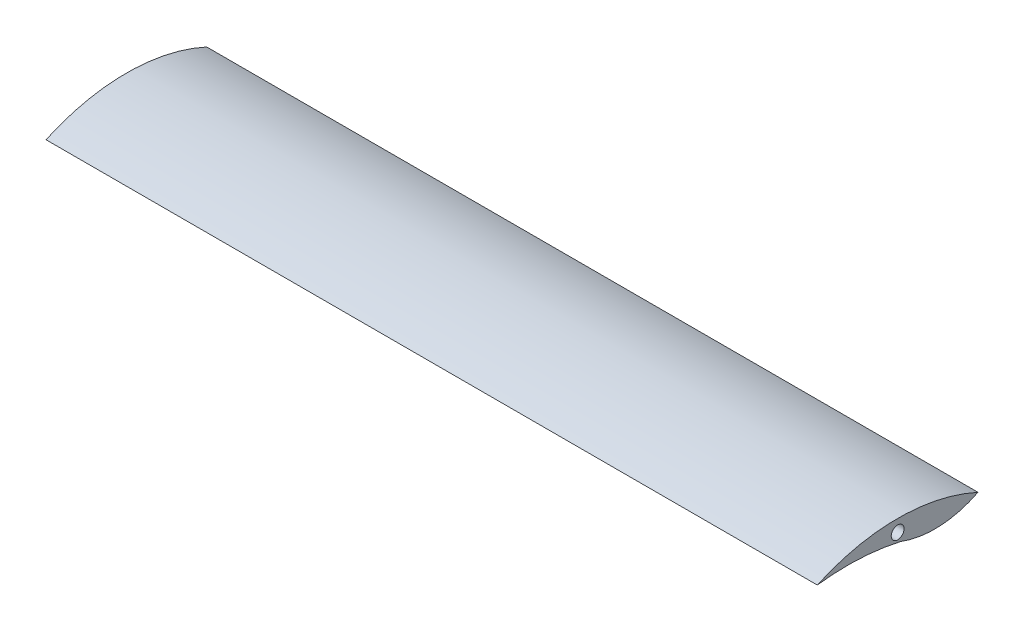
from build123d import *

# Parameters (mm, degrees)
BOSS_EXTRUDE2_DEPTH = 1200
SKETCH4_R           = 10
CUT_EXTRUDE2_DEPTH  = 30
SKETCH5_R           = 10
BOSS_EXTRUDE3_DEPTH = 20
SCALE1_SCALE        = 0.15
SKETCH8_R           = 1.423275346
SKETCH8_R_2         = 1.5
BOSS_EXTRUDE4_DEPTH = 2.5


with BuildPart() as part:
    # Sketch2 → Boss-Extrude2 (new body)
    with BuildSketch(Plane(origin=(0, 0, 0), x_dir=(0, 0, -1), z_dir=(1, 0, 0))):
        with BuildLine():
            ThreePointArc((-77.006621836, 0), (47.993378164, 27.282197134), (172.993378164, 0))
            ThreePointArc((172.993378164, 0), (113.40797201, -15.816647718), (52.515991285, -6.18577782))
            ThreePointArc((52.515991285, -6.18577782), (-11.973891604, 2.590390407), (-77.006621836, 0))
        make_face()
    extrude(amount=BOSS_EXTRUDE2_DEPTH)

    # Sketch4 → Cut-Extrude2 (cut)
    with BuildSketch(Plane.ZY):
        with Locations((-47.993378164, 8.438388981)):
            Circle(SKETCH4_R)
    cut_extrude2 = extrude(amount=-CUT_EXTRUDE2_DEPTH, mode=Mode.SUBTRACT)

    # Mirror1: Cut-Extrude2 across plane
    add(cut_extrude2.mirror(Plane(origin=(600, 0, 0), x_dir=(0, 0, 1), z_dir=(1, 0, 0))), mode=Mode.SUBTRACT)

    # Sketch5 → Boss-Extrude3 (add)
    with BuildSketch(Plane(origin=(800, 0, 0), x_dir=(0, 0, -1), z_dir=(1, 0, 0))):
        with BuildLine():
            Line((81.410704846, -14.011940423), (85.13998826, -17.780929187))
            ThreePointArc((85.13998826, -17.780929187), (85.592469343, -18.332508198), (85.935038434, -18.958307649))
            ThreePointArc((85.935038434, -18.958307649), (94.512681221, -52.437390339), (110.389076807, -21.739426291))
            ThreePointArc((110.389076807, -21.739426291), (109.883111494, -19.399677201), (111.633319944, -17.766521641))
            Line((111.633319944, -17.766521641), (119.894685982, -15.3415971))
            Line((119.894685982, -15.3415971), (121.619163907, -14.881341581))
            ThreePointArc((121.619163907, -14.881341581), (101.241742119, -14.900548765), (80.905670019, -13.602912771))
            Line((80.905670019, -13.602912771), (81.410704846, -14.011940423))
        make_face()
        with Locations((96.602298961, -34.063635389)):
            Circle(SKETCH5_R, mode=Mode.SUBTRACT)
        with BuildLine():
            Line((0, 1.824950196), (0, -28.482665363))
            ThreePointArc((0, -28.482665363), (20.687062812, -54.790757496), (34.369104077, -24.247803704))
            Line((34.369104077, -24.247803704), (34.369104077, -2.546400914))
            ThreePointArc((34.369104077, -2.546400914), (17.235436494, 0.039346175), (0, 1.824950196))
        make_face()
        with Locations((18.091069948, -35.85231876)):
            Circle(SKETCH5_R, mode=Mode.SUBTRACT)
    extrude(amount=-BOSS_EXTRUDE3_DEPTH)


with BuildPart() as part_1:
    # Scale1: scaled about (601.252748222, 6.649777436, -64.506234279)
    add(part.part.scale(SCALE1_SCALE).moved(Location((511.064835989, 5.652310821, -54.830299137))))

    # Sketch8 → Boss-Extrude4 (add)
    with BuildSketch(Plane(origin=(572.064835989, 0, 0), x_dir=(0, 0, -1), z_dir=(1, 0, 0))):
        with BuildLine():
            Line((54.830299137, 5.92605335), (54.830299137, 1.379911016))
            ThreePointArc((54.830299137, 1.379911016), (57.933358559, -2.566302804), (59.985664749, 2.015140265))
            Line((59.985664749, 2.015140265), (59.985664749, 5.270350684))
            Line((59.985664749, 5.270350684), (56.48845574, 5.92605335))
            Line((56.48845574, 5.92605335), (54.830299137, 5.92605335))
        make_face()
        with Locations((57.574663837, 0.344776051)):
            Circle(SKETCH8_R, mode=Mode.SUBTRACT)
        with BuildLine():
            Line((67.041904864, 3.550519757), (67.669169538, 2.902434591))
            Line((67.669169538, 2.902434591), (67.720554902, 2.808564673))
            ThreePointArc((67.720554902, 2.808564673), (69.00720132, -2.21329773), (71.388660658, 2.391396877))
            ThreePointArc((71.388660658, 2.391396877), (71.312765861, 2.742359241), (71.575297129, 2.987332575))
            Line((71.575297129, 2.987332575), (72.814502034, 3.351071256))
            ThreePointArc((72.814502034, 3.351071256), (69.921739963, 3.263724136), (67.041904864, 3.550519757))
        make_face()
        with Locations((69.320643981, 0.542765513)):
            Circle(SKETCH8_R_2, mode=Mode.SUBTRACT)
    extrude(amount=BOSS_EXTRUDE4_DEPTH)


solid = part_1.part
